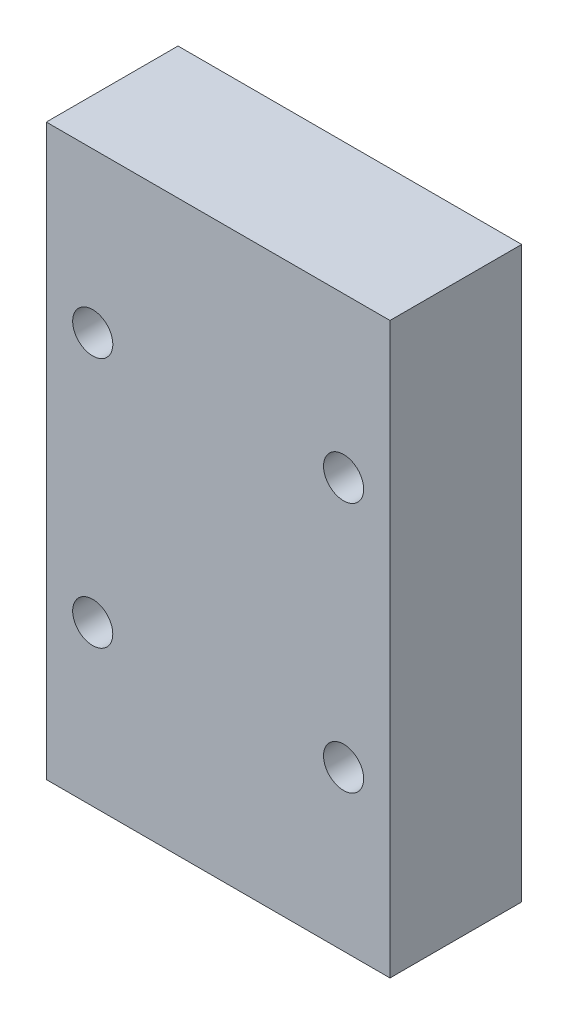
from build123d import *

# Parameters (mm, degrees)
SKETCH1_W                = 27.4
SKETCH1_H                = 45.4
SKETCH1_R                = 1.6
SKETCH1_R_2              = 1.599999998
BOSS_EXTRUDE1_DEPTH      = 5
BOSS_EXTRUDE1_DEPTH_BACK = 5.5


with BuildPart() as part:
    # Sketch1 → Boss-Extrude1 (new body, two sides)
    with BuildSketch(Plane.XY) as boss_extrude1_sk:
        with Locations((440.461848113, -60.80586409)):
            Rectangle(SKETCH1_W, SKETCH1_H)
        with Locations((430.461848113, -70.80586409)):
            Circle(SKETCH1_R, mode=Mode.SUBTRACT)
        with Locations((430.461848113, -50.80586409)):
            Circle(SKETCH1_R_2, mode=Mode.SUBTRACT)
        with Locations((450.461848113, -50.80586409)):
            Circle(SKETCH1_R_2, mode=Mode.SUBTRACT)
        with Locations((450.461848113, -70.80586409)):
            Circle(SKETCH1_R, mode=Mode.SUBTRACT)
    extrude(amount=BOSS_EXTRUDE1_DEPTH)
    extrude(boss_extrude1_sk.sketch, amount=-BOSS_EXTRUDE1_DEPTH_BACK)


solid = part.part
